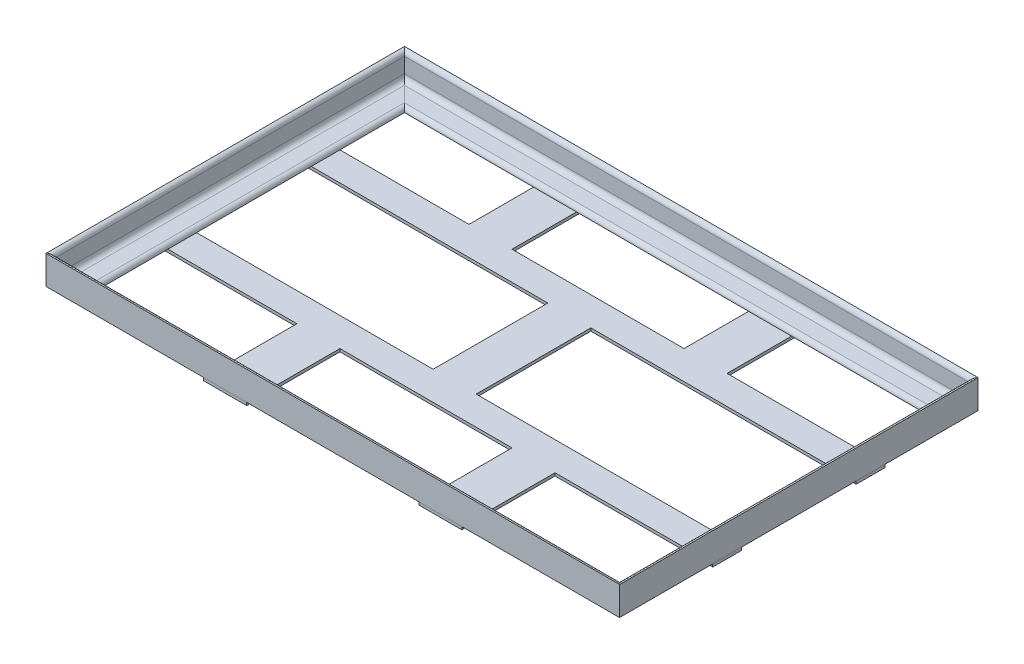
from build123d import *

# Parameters (mm, degrees)
HIERRO_ANGULAR_20_X_20_X_3_1_DEPTH      = 429.284271247
HIERRO_ANGULAR_20_X_20_X_3_1_DEPTH_BACK = 29.284271247
HIERRO_ANGULAR_20_X_20_X_3_1_2_DEPTH    = 308.568542495
HIERRO_ANGULAR_20_X_20_X_3_1_3_DEPTH    = 458.568542495
HIERRO_ANGULAR_20_X_20_X_3_1_4_DEPTH    = 308.568542495
SALIENTE_EXTRUIR1_DEPTH                 = 2


with BuildPart() as part:
    # Sketch1 → Hierro angular 20 X 20 X 3(1) (new, two sides)
    with BuildSketch(Plane(origin=(-200, 0, 125), x_dir=(0, 0, -1), z_dir=(1, 0, 0))) as hierro_angular_20_x_20_x_3_1_sk:
        with BuildLine():
            Line((0, 0), (0, 20))
            ThreePointArc((0, 20), (2.121320344, 19.121320344), (3, 17))
            Line((3, 17), (3, 6.5))
            ThreePointArc((3, 6.5), (4.025126266, 4.025126266), (6.5, 3))
            Line((6.5, 3), (17, 3))
            ThreePointArc((17, 3), (19.121320344, 2.121320344), (20, 0))
            Line((20, 0), (0, 0))
        make_face()
    extrude(amount=HIERRO_ANGULAR_20_X_20_X_3_1_DEPTH)
    extrude(hierro_angular_20_x_20_x_3_1_sk.sketch, amount=-HIERRO_ANGULAR_20_X_20_X_3_1_DEPTH_BACK)

    # Hierro angular 20 X 20 X 3(1) mitre 1
    split(bisect_by=Plane(origin=(-200, 0, 125), x_dir=(0, 1, 0), z_dir=(0.707106781, 0, 0.707106781)), keep=Keep.TOP)

    # Hierro angular 20 X 20 X 3(1) mitre 2
    split(bisect_by=Plane(origin=(200, 0, 125), x_dir=(0, -1, 0), z_dir=(-0.707106781, 0, 0.707106781)), keep=Keep.TOP)


with BuildPart() as body_2:
    # Sketch1 on segment 2 (carried to segment 2) → Hierro angular 20 X 20 X 3_1 2 (new body)
    with BuildSketch(Plane(origin=(200, 0, 154.284271247), x_dir=(-1, 0, 0), z_dir=(0, 0, -1))):
        with BuildLine():
            Line((0, 0), (0, 20))
            ThreePointArc((0, 20), (2.121320344, 19.121320344), (3, 17))
            Line((3, 17), (3, 6.5))
            ThreePointArc((3, 6.5), (4.025126266, 4.025126266), (6.5, 3))
            Line((6.5, 3), (17, 3))
            ThreePointArc((17, 3), (19.121320344, 2.121320344), (20, 0))
            Line((20, 0), (0, 0))
        make_face()
    extrude(amount=HIERRO_ANGULAR_20_X_20_X_3_1_2_DEPTH)

    # Hierro angular 20 X 20 X 3_1 2 mitre 1
    split(bisect_by=Plane(origin=(200, 0, 125), x_dir=(0, 1, 0), z_dir=(0.707106781, 0, -0.707106781)), keep=Keep.TOP)

    # Hierro angular 20 X 20 X 3_1 2 mitre 2
    split(bisect_by=Plane(origin=(200, 0, -125), x_dir=(0, 1, 0), z_dir=(0.707106781, 0, 0.707106781)), keep=Keep.TOP)


with BuildPart() as body_3:
    # Sketch1 on segment 3 (carried to segment 3) → Hierro angular 20 X 20 X 3_1 3 (new body)
    with BuildSketch(Plane(origin=(229.284271247, 0, -125), x_dir=(0, 0, 1), z_dir=(-1, 0, 0))):
        with BuildLine():
            Line((0, 0), (0, 20))
            ThreePointArc((0, 20), (2.121320344, 19.121320344), (3, 17))
            Line((3, 17), (3, 6.5))
            ThreePointArc((3, 6.5), (4.025126266, 4.025126266), (6.5, 3))
            Line((6.5, 3), (17, 3))
            ThreePointArc((17, 3), (19.121320344, 2.121320344), (20, 0))
            Line((20, 0), (0, 0))
        make_face()
    extrude(amount=HIERRO_ANGULAR_20_X_20_X_3_1_3_DEPTH)

    # Hierro angular 20 X 20 X 3_1 3 mitre 1
    split(bisect_by=Plane(origin=(-200, 0, -125), x_dir=(0, 1, 0), z_dir=(0.707106781, 0, -0.707106781)), keep=Keep.TOP)

    # Hierro angular 20 X 20 X 3_1 3 mitre 2
    split(bisect_by=Plane(origin=(200, 0, -125), x_dir=(0, -1, 0), z_dir=(-0.707106781, 0, -0.707106781)), keep=Keep.TOP)


with BuildPart() as body_4:
    # Sketch1 on segment 4 (carried to segment 4) → Hierro angular 20 X 20 X 3_1 4 (new body)
    with BuildSketch(Plane(origin=(-200, 0, -154.284271247), x_dir=(1, 0, 0), z_dir=(0, 0, 1))):
        with BuildLine():
            Line((0, 0), (0, 20))
            ThreePointArc((0, 20), (2.121320344, 19.121320344), (3, 17))
            Line((3, 17), (3, 6.5))
            ThreePointArc((3, 6.5), (4.025126266, 4.025126266), (6.5, 3))
            Line((6.5, 3), (17, 3))
            ThreePointArc((17, 3), (19.121320344, 2.121320344), (20, 0))
            Line((20, 0), (0, 0))
        make_face()
    extrude(amount=HIERRO_ANGULAR_20_X_20_X_3_1_4_DEPTH)

    # Hierro angular 20 X 20 X 3_1 4 mitre 1
    split(bisect_by=Plane(origin=(-200, 0, 125), x_dir=(0, -1, 0), z_dir=(-0.707106781, 0, -0.707106781)), keep=Keep.TOP)

    # Hierro angular 20 X 20 X 3_1 4 mitre 2
    split(bisect_by=Plane(origin=(-200, 0, -125), x_dir=(0, -1, 0), z_dir=(-0.707106781, 0, 0.707106781)), keep=Keep.TOP)


with BuildPart() as body_5:
    # Croquis3 → Saliente-Extruir1 (new body)
    with BuildSketch(Plane.XZ):
        Polygon((-200, -60), (-90, -60), (-90, -125), (-60, -125), (-60, -60), (-15, -60), (15, -60), (60, -60), (60, -125), (90, -125), (90, -60), (200, -60), (200, -40), (15, -40), (15, 40), (200, 40), (200, 60), (90, 60), (90, 125), (60, 125), (60, 60), (15, 60), (-15, 60), (-60, 60), (-60, 125), (-90, 125), (-90, 60), (-200, 60), (-200, 40), (-15, 40), (-15, -40), (-200, -40), align=None)
    extrude(amount=SALIENTE_EXTRUIR1_DEPTH)


solid = Compound([part.part, body_2.part, body_3.part, body_4.part, body_5.part])
